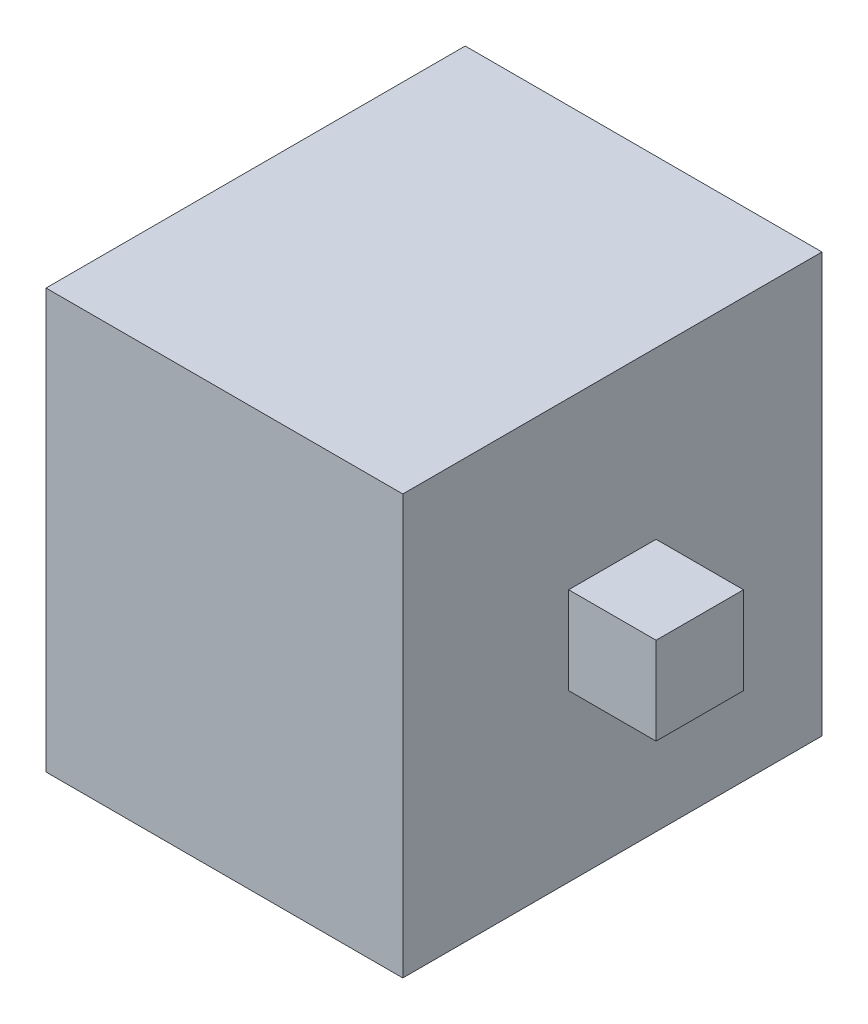
from build123d import *

# Parameters (mm, degrees)
CROQUIS1_W              = 200
CROQUIS1_H              = 235
SALIENTE_EXTRUIR1_DEPTH = 235
CROQUIS2_W              = 49
CROQUIS2_H              = 49
SALIENTE_EXTRUIR2_DEPTH = 49


with BuildPart() as part:
    # Croquis1 → Saliente-Extruir1 (new body)
    with BuildSketch(Plane.XY):
        Rectangle(CROQUIS1_W, CROQUIS1_H)
    extrude(amount=SALIENTE_EXTRUIR1_DEPTH)

    # Croquis2 → Saliente-Extruir2 (add)
    with BuildSketch(Plane(origin=(100, 0, 0), x_dir=(0, 0, -1), z_dir=(1, 0, 0))):
        with Locations((-117.5, 0)):
            Rectangle(CROQUIS2_W, CROQUIS2_H)
    extrude(amount=SALIENTE_EXTRUIR2_DEPTH)


solid = part.part
